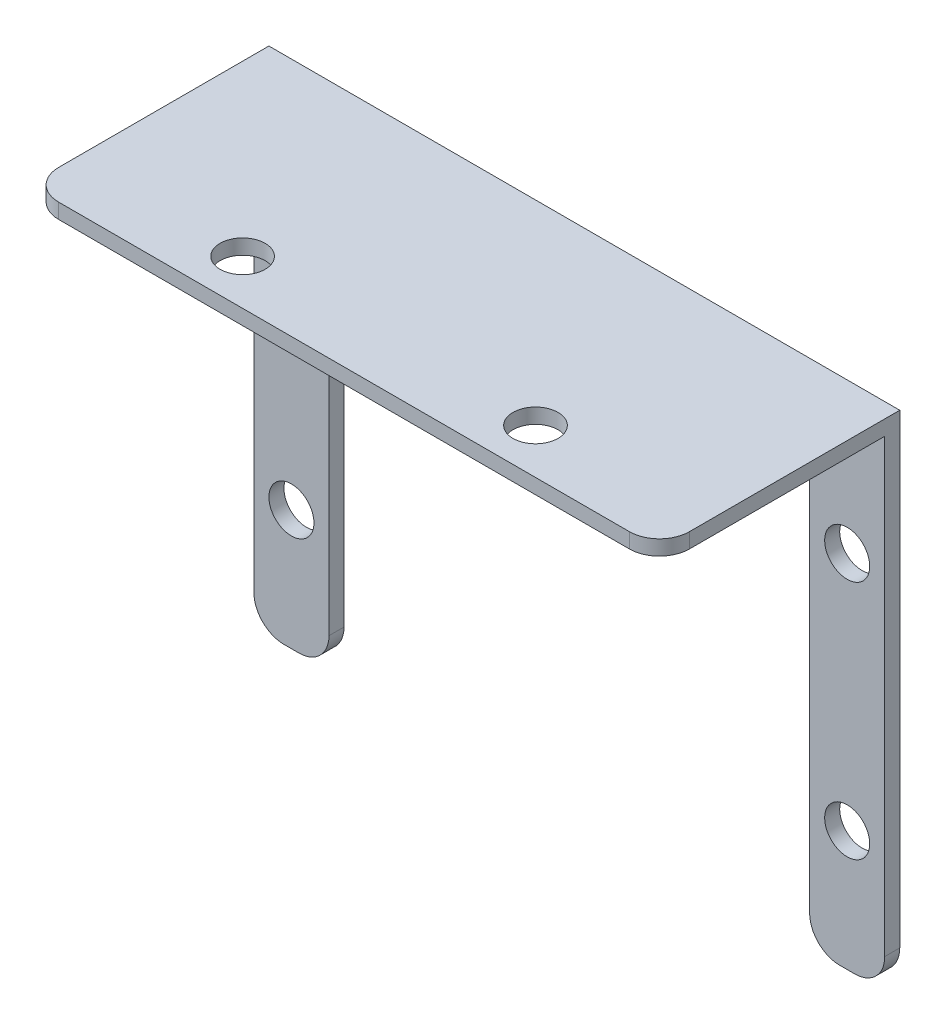
from build123d import *

# Parameters (mm, degrees)
IR_HOLDER_SKETCH_W        = 42
IR_HOLDER_SKETCH_H        = 16
IR_HOLDER_DEPTH           = 1
ATTACHMENT_SKETCH_W       = 5
ATTACHMENT_SKETCH_H       = 1
ATTACHMENT_TO_BASE_DEPTH  = 32
ATTACHMENT_HOLES_REACH    = 18
ATTACHMENT_HOLES_SKETCH_R = 1.5
IR_HOLES_REACH            = 35
IR_HOLES_SKETCH_R         = 1.5
DONT_CUT_URSELF_R         = 2


with BuildPart() as part:
    # IR Holder Sketch → IR Holder (new body)
    with BuildSketch(Plane(origin=(0, 0, 0), x_dir=(1, 0, 0), z_dir=(0, 1, 0))):
        with Locations((21, -8)):
            Rectangle(IR_HOLDER_SKETCH_W, IR_HOLDER_SKETCH_H)
    extrude(amount=IR_HOLDER_DEPTH)

    # Attachment Sketch → Attachment to Base (add)
    with BuildSketch(Plane.XZ):
        with Locations((39.5, 0.5)):
            Rectangle(ATTACHMENT_SKETCH_W, ATTACHMENT_SKETCH_H)
        with Locations((2.5, 0.5)):
            Rectangle(ATTACHMENT_SKETCH_W, ATTACHMENT_SKETCH_H)
    extrude(amount=ATTACHMENT_TO_BASE_DEPTH)

    # Attachment Holes Sketch → Attachment Holes (cut, up to next)
    with BuildSketch(Plane(origin=(0, 0, 0), x_dir=(-1, 0, 0), z_dir=(0, 0, -1)), mode=Mode.PRIVATE) as attachment_holes_sk1:
        with Locations((-39.5, -8)):
            Circle(ATTACHMENT_HOLES_SKETCH_R)
    attachment_holes_tool1 = extrude(attachment_holes_sk1.sketch, amount=-ATTACHMENT_HOLES_REACH, mode=Mode.PRIVATE) & part.part
    add(attachment_holes_tool1.solids().sort_by_distance((39.5, -8, 0))[0], mode=Mode.SUBTRACT)
    # Attachment Holes Sketch → Attachment Holes (cut, up to next)
    with BuildSketch(Plane(origin=(0, 0, 0), x_dir=(-1, 0, 0), z_dir=(0, 0, -1)), mode=Mode.PRIVATE) as attachment_holes_sk2:
        with Locations((-39.5, -24)):
            Circle(ATTACHMENT_HOLES_SKETCH_R)
    attachment_holes_tool2 = extrude(attachment_holes_sk2.sketch, amount=-ATTACHMENT_HOLES_REACH, mode=Mode.PRIVATE) & part.part
    add(attachment_holes_tool2.solids().sort_by_distance((39.5, -24, 0))[0], mode=Mode.SUBTRACT)
    # Attachment Holes Sketch → Attachment Holes (cut, up to next)
    with BuildSketch(Plane(origin=(0, 0, 0), x_dir=(-1, 0, 0), z_dir=(0, 0, -1)), mode=Mode.PRIVATE) as attachment_holes_sk3:
        with Locations((-2.5, -24)):
            Circle(ATTACHMENT_HOLES_SKETCH_R)
    attachment_holes_tool3 = extrude(attachment_holes_sk3.sketch, amount=-ATTACHMENT_HOLES_REACH, mode=Mode.PRIVATE) & part.part
    add(attachment_holes_tool3.solids().sort_by_distance((2.5, -24, 0))[0], mode=Mode.SUBTRACT)
    # Attachment Holes Sketch → Attachment Holes (cut, up to next)
    with BuildSketch(Plane(origin=(0, 0, 0), x_dir=(-1, 0, 0), z_dir=(0, 0, -1)), mode=Mode.PRIVATE) as attachment_holes_sk4:
        with Locations((-2.5, -8)):
            Circle(ATTACHMENT_HOLES_SKETCH_R)
    attachment_holes_tool4 = extrude(attachment_holes_sk4.sketch, amount=-ATTACHMENT_HOLES_REACH, mode=Mode.PRIVATE) & part.part
    add(attachment_holes_tool4.solids().sort_by_distance((2.5, -8, 0))[0], mode=Mode.SUBTRACT)

    # IR Holes Sketch → IR Holes (cut, up to next)
    with BuildSketch(Plane(origin=(0, 1, 0), x_dir=(1, 0, 0), z_dir=(0, 1, 0)), mode=Mode.PRIVATE) as ir_holes_sk1:
        with Locations((30.75, -13)):
            Circle(IR_HOLES_SKETCH_R)
    ir_holes_tool1 = extrude(ir_holes_sk1.sketch, amount=-IR_HOLES_REACH, mode=Mode.PRIVATE) & part.part
    add(ir_holes_tool1.solids().sort_by_distance((30.75, 1, 13))[0], mode=Mode.SUBTRACT)
    # IR Holes Sketch → IR Holes (cut, up to next)
    with BuildSketch(Plane(origin=(0, 1, 0), x_dir=(1, 0, 0), z_dir=(0, 1, 0)), mode=Mode.PRIVATE) as ir_holes_sk2:
        with Locations((11.25, -13)):
            Circle(IR_HOLES_SKETCH_R)
    ir_holes_tool2 = extrude(ir_holes_sk2.sketch, amount=-IR_HOLES_REACH, mode=Mode.PRIVATE) & part.part
    add(ir_holes_tool2.solids().sort_by_distance((11.25, 1, 13))[0], mode=Mode.SUBTRACT)

    # Dont cut urself
    dont_cut_urself_edges = [part.edges().sort_by_distance(p)[0] for p in [
        (42, -32, 0.5),
        (37, -32, 0.5),
        (5, -32, 0.5),
        (0, -32, 0.5),
        (42, 0.5, 16),
        (0, 0.5, 16),
    ]]
    fillet(dont_cut_urself_edges, radius=DONT_CUT_URSELF_R)


solid = part.part
